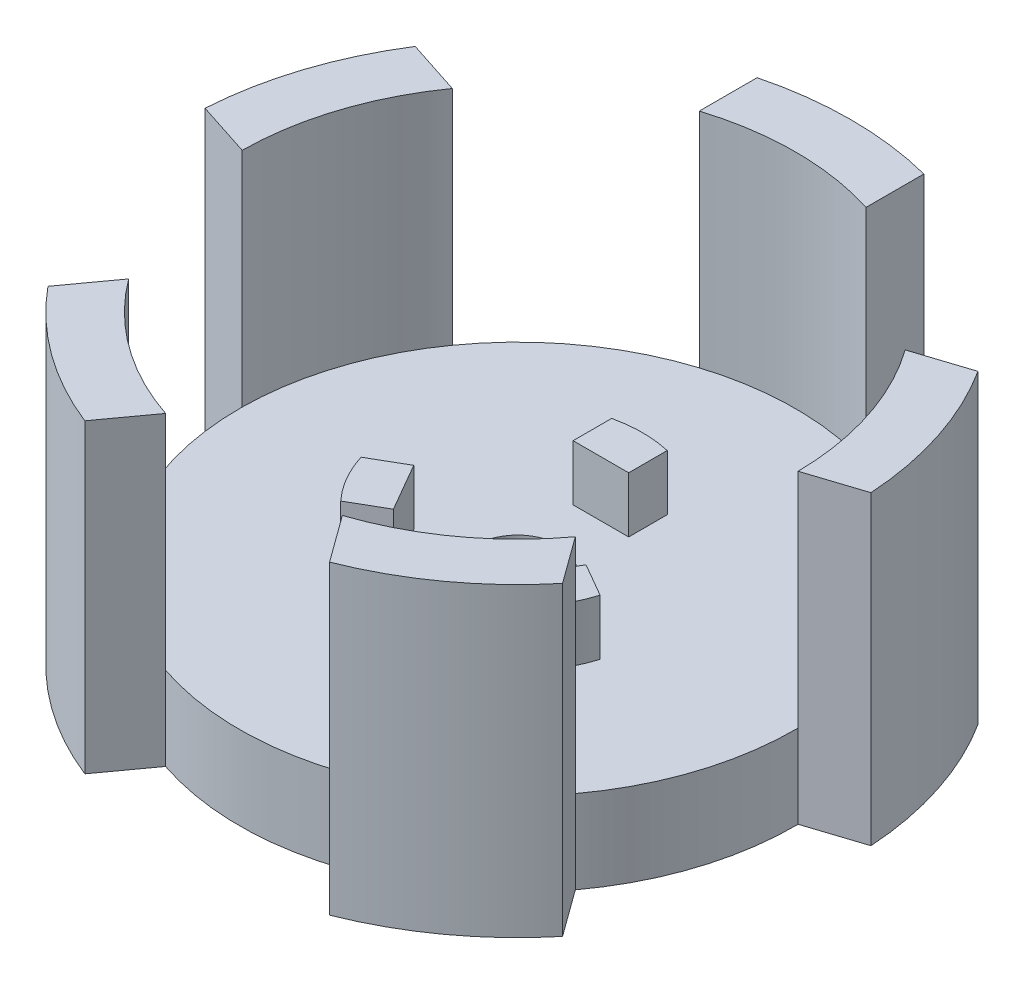
from build123d import *

# Parameters (mm, degrees)
SKETCH1_R           = 10
BOSS_EXTRUDE1_DEPTH = 3
SKETCH2_W           = 2
SKETCH2_H           = 3
BOSS_EXTRUDE2_DEPTH = 2
CIRPATTERN1_COUNT   = 3
SKETCH3_R           = 9
SKETCH3_R_2         = 4.5
CUT_EXTRUDE1_DEPTH  = 2
SKETCH4_R           = 1.5
CUT_EXTRUDE2_DEPTH  = 3
BOSS_EXTRUDE3_START = -3
BOSS_EXTRUDE3_DEPTH = 11
CIRPATTERN2_COUNT   = 5


with BuildPart() as part:
    # Sketch1 → Boss-Extrude1 (new body)
    with BuildSketch(Plane(origin=(0, 0, 0), x_dir=(1, 0, 0), z_dir=(0, 1, 0))):
        Circle(SKETCH1_R)
    extrude(amount=BOSS_EXTRUDE1_DEPTH)

    # Sketch2 → Boss-Extrude2 (add)
    with BuildSketch(Plane(origin=(0, 3, 0), x_dir=(1, 0, 0), z_dir=(0, 1, 0))):
        with Locations((0, 4.5)):
            Rectangle(SKETCH2_W, SKETCH2_H)
    boss_extrude2 = extrude(amount=BOSS_EXTRUDE2_DEPTH)

    # CirPattern1: Boss-Extrude2 ×3 about axis
    cirpattern1_axis = Axis((0, 0, 0), (0, 1, 0))
    for i in range(1, CIRPATTERN1_COUNT):
        add(boss_extrude2.rotate(cirpattern1_axis, i * 360 / CIRPATTERN1_COUNT))

    # Sketch3 → Cut-Extrude1 (cut)
    with BuildSketch(Plane(origin=(0, 3, 0), x_dir=(1, 0, 0), z_dir=(0, 1, 0))):
        Circle(SKETCH3_R)
        Circle(SKETCH3_R_2, mode=Mode.SUBTRACT)
    extrude(amount=CUT_EXTRUDE1_DEPTH, mode=Mode.SUBTRACT)

    # Sketch4 → Cut-Extrude2 (cut)
    with BuildSketch(Plane(origin=(0, 3, 0), x_dir=(1, 0, 0), z_dir=(0, 1, 0))):
        Circle(SKETCH4_R)
    extrude(amount=-CUT_EXTRUDE2_DEPTH, mode=Mode.SUBTRACT)

    # Sketch5 → Boss-Extrude3 (add)
    with BuildSketch(Plane(origin=(0, 3, 0), x_dir=(1, 0, 0), z_dir=(0, 1, 0)).offset(BOSS_EXTRUDE3_START)):
        with BuildLine():
            ThreePointArc((3, 11.618950039), (1.51205151, 11.904356355), (0, 12))
            ThreePointArc((0, 12), (-1.51205151, 11.904356355), (-3, 11.618950039))
            Line((-3, 11.618950039), (-3, 9.539392014))
            ThreePointArc((-3, 9.539392014), (0, 10), (3, 9.539392014))
            Line((3, 9.539392014), (3, 11.618950039))
        make_face()
    boss_extrude3 = extrude(amount=BOSS_EXTRUDE3_DEPTH)

    # CirPattern2: Boss-Extrude3 ×5 about axis
    cirpattern2_axis = Axis((0, 0, 0), (0, 1, 0))
    for i in range(1, CIRPATTERN2_COUNT):
        add(boss_extrude3.rotate(cirpattern2_axis, i * 360 / CIRPATTERN2_COUNT))


solid = part.part
